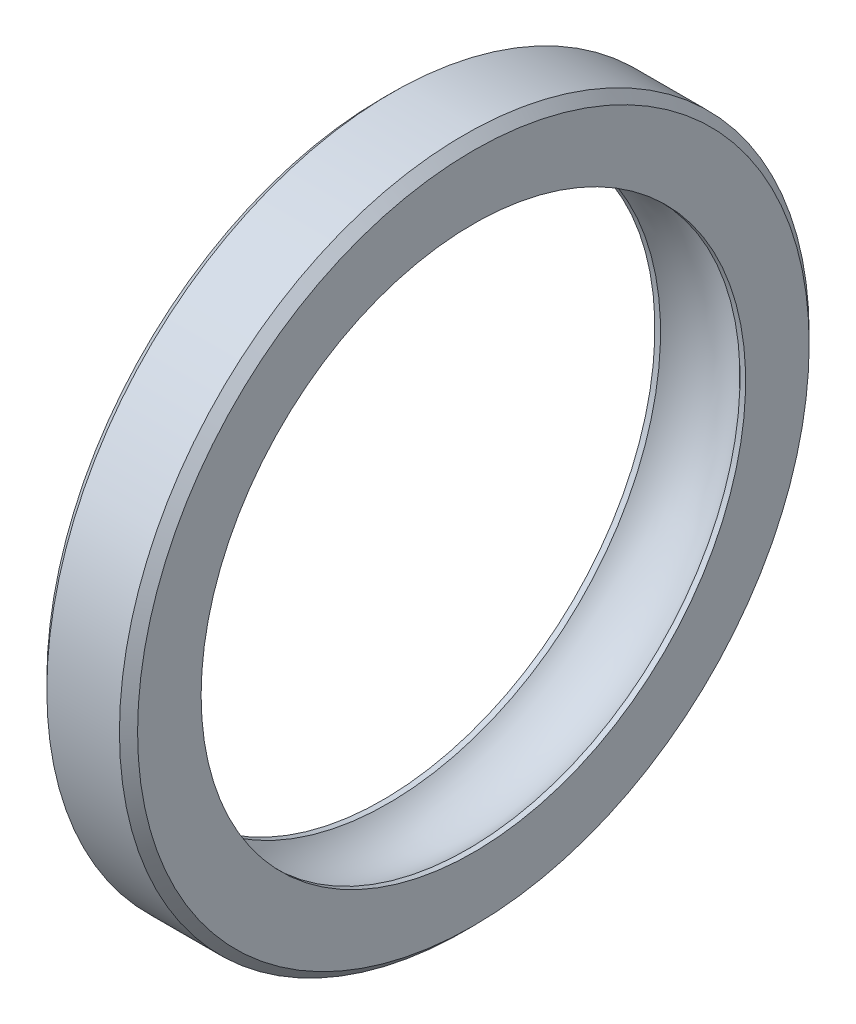
from build123d import *

# Parameters (mm, degrees)
CHAMFER2_SIZE = 0.5


with BuildPart() as part:
    # Sketch1 → Revolve2 (revolve)
    with BuildSketch(Plane.XY):
        with BuildLine():
            Line((-2.5, 15), (-2.188493664, 15))
            ThreePointArc((-2.188493664, 15), (0, 15.948050809), (2.188493664, 15))
            Line((2.188493664, 15), (2.5, 15))
            Line((2.5, 15), (2.5, 19))
            Line((2.5, 19), (-2.5, 19))
            Line((-2.5, 19), (-2.5, 15))
        make_face()
    revolve(axis=Axis((-21.395056223, 0, 0), (1, 0, 0)))

    # Chamfer2
    chamfer2_edges = [part.edges().sort_by_distance(p)[0] for p in [
        (-2.5, -19, 0),
        (2.5, -19, 0),
    ]]
    chamfer(chamfer2_edges, length=CHAMFER2_SIZE)


solid = part.part
